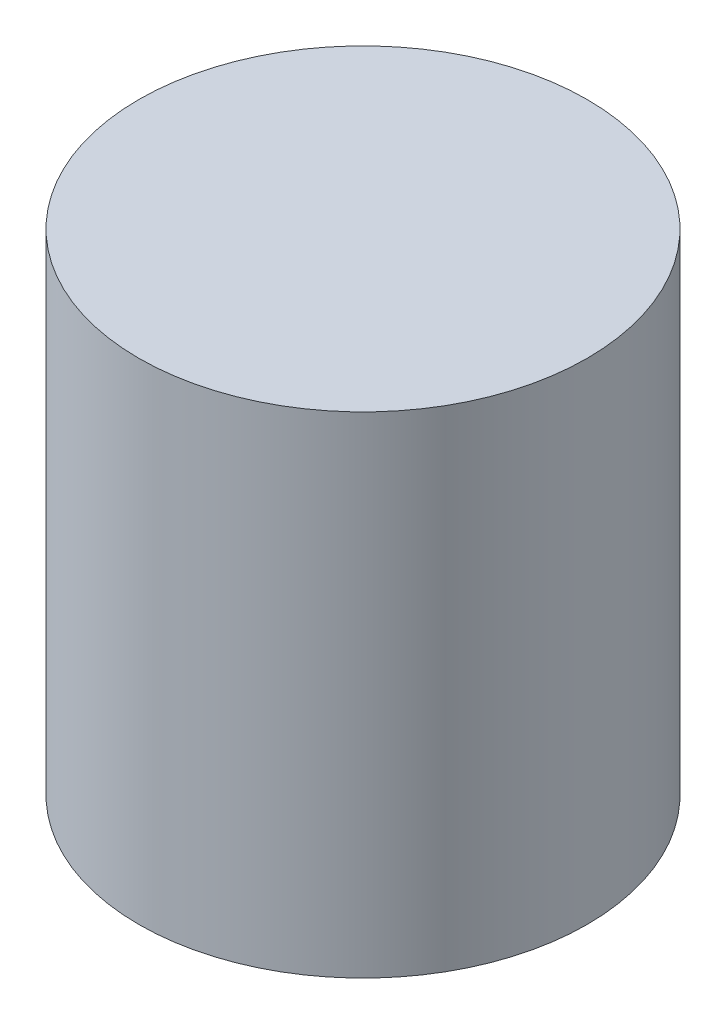
from build123d import *

# Parameters (mm, degrees)
SKETCH_1_R      = 16
EXTRUDE_1_DEPTH = 35


with BuildPart() as part:
    # Эскиз1 → Бобышка-Вытянуть1 (new body)
    with BuildSketch(Plane(origin=(0, 0, 0), x_dir=(1, 0, 0), z_dir=(0, 1, 0))):
        Circle(SKETCH_1_R)
    extrude(amount=EXTRUDE_1_DEPTH)


solid = part.part
